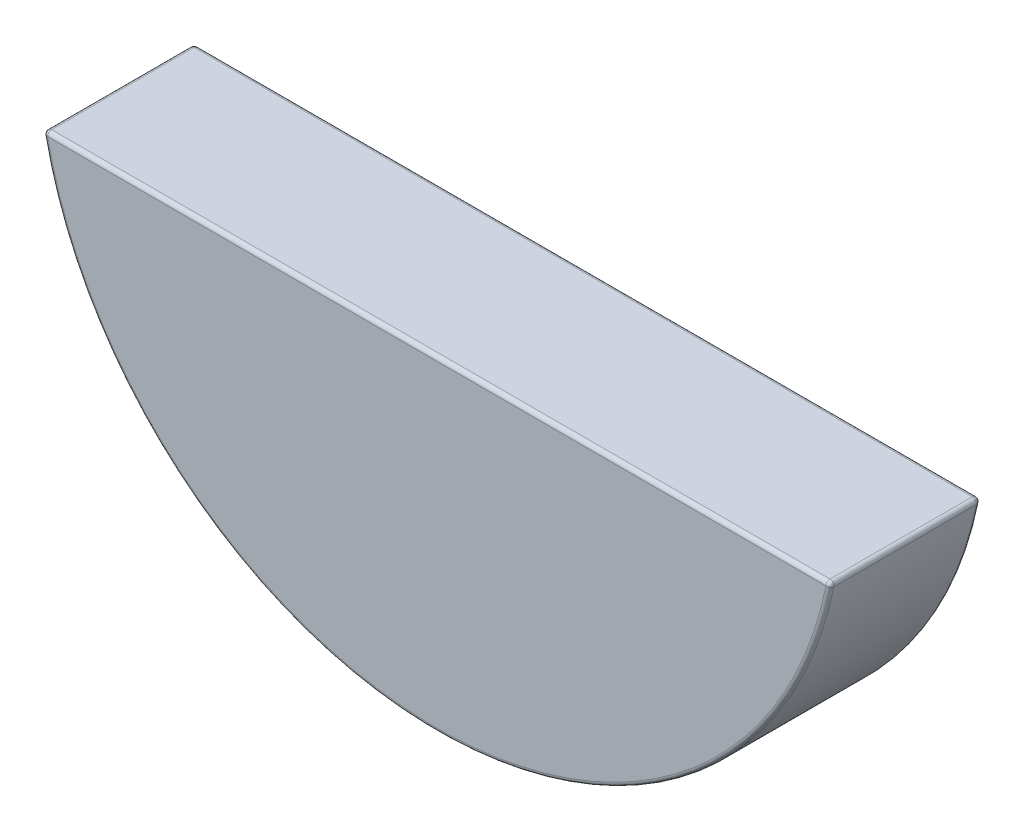
from build123d import *

# Parameters (mm, degrees)
EXTRUDE1_DEPTH = 2.38125
FILLET3_R      = 0.0635


with BuildPart() as part:
    # Sketch1 → Extrude1 (new body)
    with BuildSketch(Plane.XY):
        with BuildLine():
            Line((-6.236773329, -1.1938), (6.236773329, -1.1938))
            ThreePointArc((6.236773329, -1.1938), (0, -6.35), (-6.236773329, -1.1938))
        make_face()
    extrude(amount=EXTRUDE1_DEPTH)

    # Fillet3
    fillet3_edges = [part.edges().sort_by_distance(p)[0] for p in [
        (0, -1.1938, 0),
        (0, -6.35, 0),
        (0, -6.35, 2.38125),
        (-6.236773329, -1.1938, 1.190625),
        (6.236773329, -1.1938, 1.190625),
        (0, -1.1938, 2.38125),
    ]]
    fillet(fillet3_edges, radius=FILLET3_R)


solid = part.part
